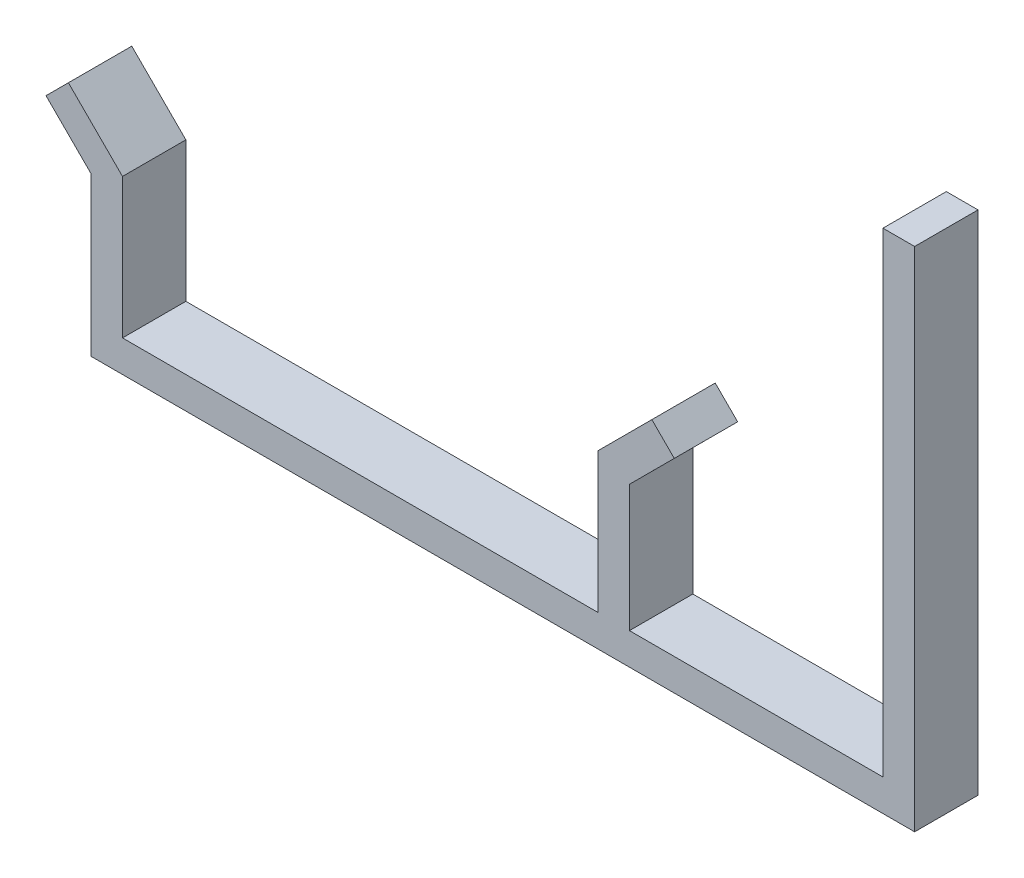
from build123d import *

# Parameters (mm, degrees)
BOSS_EXTRUDE4_DEPTH = 10


with BuildPart() as part:
    # Sketch6 → Boss-Extrude4 (new body)
    with BuildSketch(Plane.XY):
        Polygon((-61.464257477, -8.058108378), (-61.464257477, -33.058108378), (68.535915332, -33.058108378), (68.535915332, 46.941891622), (63.535915332, 46.941891622), (63.535915332, -28.058108378), (23.535915332, -28.058108378), (23.535915332, -8.058108378), (30.606393052, -0.986450524), (27.070564124, 2.548788336), (18.535742523, -5.987457815), (18.535742523, -28.058108378), (-56.464257477, -28.058108378), (-56.464257477, -5.987040567), (-65.000971617, 2.548493339), (-68.535915332, -0.987630659), align=None)
    extrude(amount=BOSS_EXTRUDE4_DEPTH)


solid = part.part
